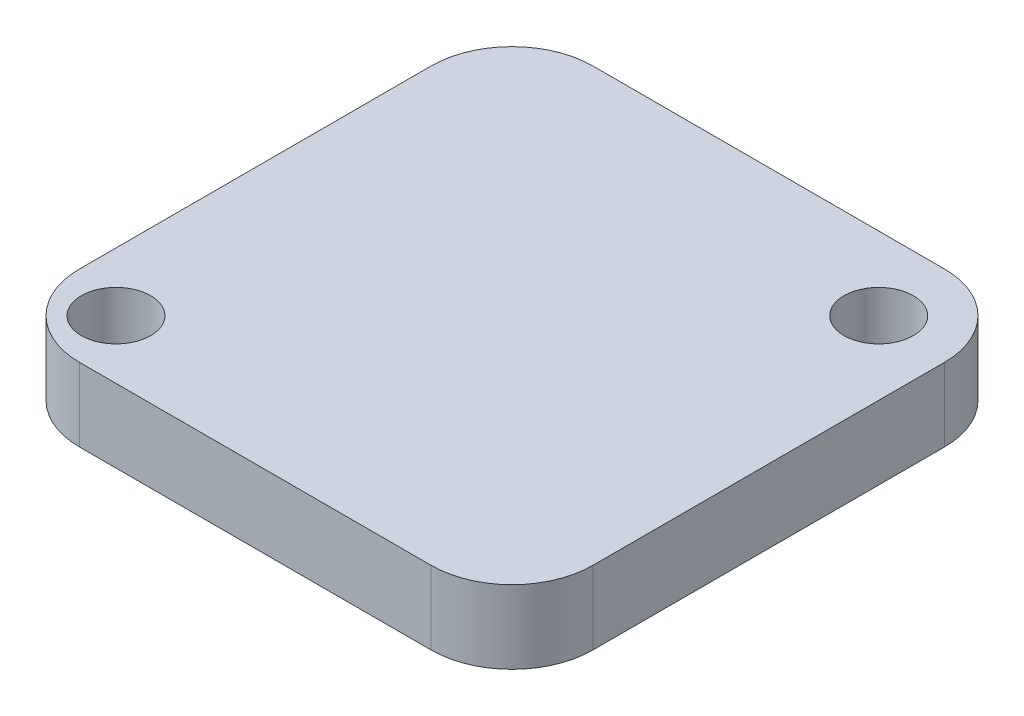
from build123d import *

# Parameters (mm, degrees)
SKETCH1_R           = 1.2
BOSS_EXTRUDE1_DEPTH = 2.54


with BuildPart() as part:
    # Sketch1 → Boss-Extrude1 (new body)
    with BuildSketch(Plane(origin=(0, 0, 0), x_dir=(1, 0, 0), z_dir=(0, 1, 0))):
        with BuildLine():
            Line((-6.0900056, 8.89), (6.0900056, 8.89))
            ThreePointArc((6.0900056, 8.89), (8.069900628, 8.069900628), (8.89, 6.0900056))
            Line((8.89, 6.0900056), (8.89, -6.0900056))
            ThreePointArc((8.89, -6.0900056), (8.069900628, -8.069900628), (6.0900056, -8.89))
            Line((6.0900056, -8.89), (-6.0900056, -8.89))
            ThreePointArc((-6.0900056, -8.89), (-8.069900628, -8.069900628), (-8.89, -6.0900056))
            Line((-8.89, -6.0900056), (-8.89, 6.0900056))
            ThreePointArc((-8.89, 6.0900056), (-8.069900628, 8.069900628), (-6.0900056, 8.89))
        make_face()
        with Locations((6.35, 6.35)):
            Circle(SKETCH1_R, mode=Mode.SUBTRACT)
        with Locations((-6.858, -6.858)):
            Circle(SKETCH1_R, mode=Mode.SUBTRACT)
    extrude(amount=BOSS_EXTRUDE1_DEPTH)


solid = part.part
